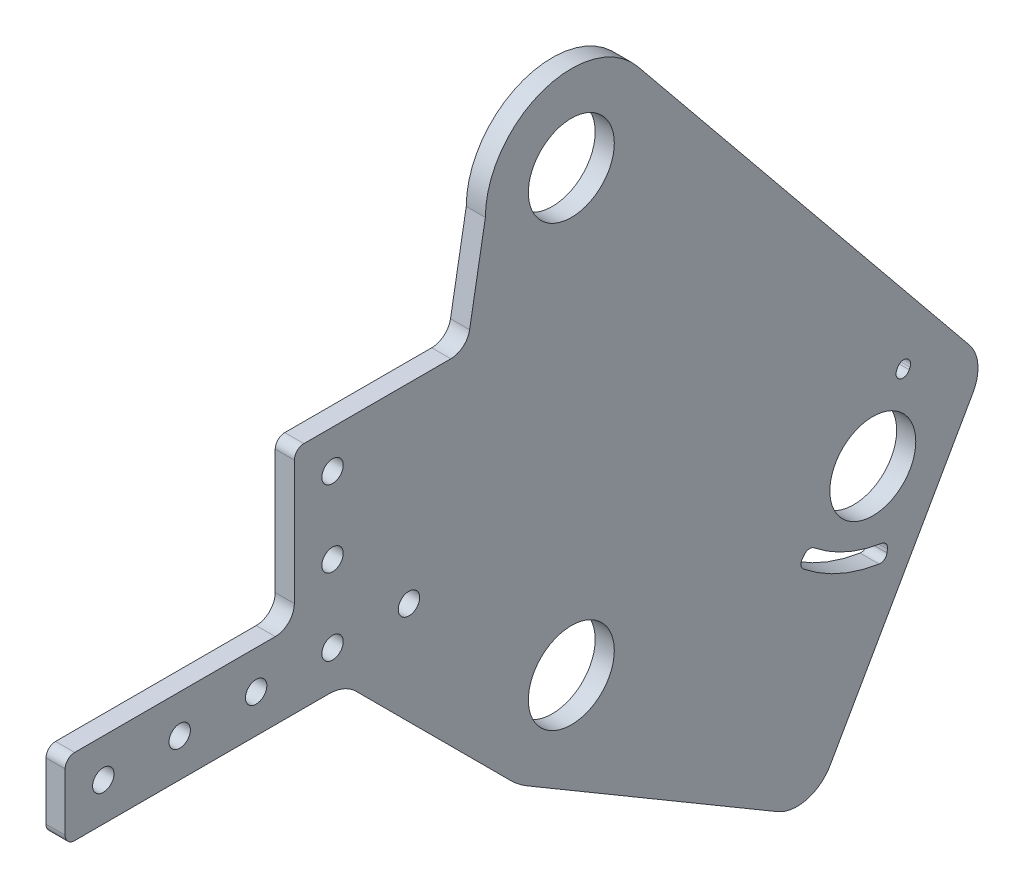
from build123d import *

# Parameters (mm, degrees)
SKETCH2_R           = 14.2875
SKETCH2_R_2         = 3.556
BOSS_EXTRUDE1_DEPTH = 6.35


with BuildPart() as part:
    # Sketch2 → Boss-Extrude1 (new body)
    with BuildSketch(Plane(origin=(0, 0, 0), x_dir=(0, 0, -1), z_dir=(1, 0, 0))):
        with BuildLine():
            Line((-165.1, 34.925), (-80.596664787, 34.925))
            ThreePointArc((-80.596664787, 34.925), (-75.736585196, 33.958270063), (-71.616408666, 31.205256121))
            Line((-71.616408666, 31.205256121), (-20.205576272, -20.205576272))
            ThreePointArc((-20.205576272, -20.205576272), (-17.495774254, -22.592664922), (-14.50653847, -24.618914814))
            Line((-14.50653847, -24.618914814), (68.578013642, -73.575957012))
            ThreePointArc((68.578013642, -73.575957012), (78.454344121, -74.862548761), (86.221769537, -68.628422964))
            Line((86.221769537, -68.628422964), (133.536181692, 14.57458872))
            ThreePointArc((133.536181692, 14.57458872), (135.152284875, 21.909694343), (132.341634936, 28.875023547))
            Line((132.341634936, 28.875023547), (22.151863474, 164.100639036))
            ThreePointArc((22.151863474, 164.100639036), (-9.579695356, 172.971368128), (-28.575, 146.05))
            Line((-28.575, 146.05), (-33.807973228, 116.372334072))
            ThreePointArc((-33.807973228, 116.372334072), (-35.979801138, 112.610617786), (-40.061502459, 111.125))
            Line((-40.061502459, 111.125), (-88.9, 111.125))
            ThreePointArc((-88.9, 111.125), (-91.14506403, 110.19506403), (-92.075, 107.95))
            Line((-92.075, 107.95), (-92.075, 66.675))
            ThreePointArc((-92.075, 66.675), (-93.934871939, 62.184871939), (-98.425, 60.325))
            Line((-98.425, 60.325), (-165.1, 60.325))
            ThreePointArc((-165.1, 60.325), (-167.34506403, 59.39506403), (-168.275, 57.15))
            Line((-168.275, 57.15), (-168.275, 38.1))
            ThreePointArc((-168.275, 38.1), (-167.34506403, 35.85493597), (-165.1, 34.925))
        make_face()
        with Locations((0, 146.05)):
            Circle(SKETCH2_R, mode=Mode.SUBTRACT)
        Circle(SKETCH2_R, mode=Mode.SUBTRACT)
        with Locations((-53.975, 47.625)):
            Circle(SKETCH2_R_2, mode=Mode.SUBTRACT)
        with Locations((-79.375, 47.625)):
            Circle(SKETCH2_R_2, mode=Mode.SUBTRACT)
        with Locations((-104.775, 47.625)):
            Circle(SKETCH2_R_2, mode=Mode.SUBTRACT)
        with Locations((-130.175, 47.625)):
            Circle(SKETCH2_R_2, mode=Mode.SUBTRACT)
        with Locations((-155.575, 47.625)):
            Circle(SKETCH2_R_2, mode=Mode.SUBTRACT)
        with Locations((100.217738322, 10.071728166)):
            Circle(SKETCH2_R, mode=Mode.SUBTRACT)
        with Locations((-79.375, 73.025)):
            Circle(SKETCH2_R_2, mode=Mode.SUBTRACT)
        with Locations((-79.375, 98.425)):
            Circle(SKETCH2_R_2, mode=Mode.SUBTRACT)
        with BuildLine():
            Line((108.137843951, 33.631444269), (108.400752916, 34.22590106))
            ThreePointArc((108.400752916, 34.22590106), (111.416042328, 35.39192926), (112.582070528, 32.376639848))
            Line((112.582070528, 32.376639848), (112.319161563, 31.782183057))
            ThreePointArc((112.319161563, 31.782183057), (109.303872151, 30.616154857), (108.137843951, 33.631444269))
        make_face(mode=Mode.SUBTRACT)
        with BuildLine():
            Line((77.477027734, -4.031327927), (76.839593557, -4.822487627))
            ThreePointArc((76.839593557, -4.822487627), (76.346823941, -6.501290334), (77.185475983, -8.036823849))
            ThreePointArc((77.185475983, -8.036823849), (89.019434317, -15.248472927), (102.316672427, -19.151537226))
            ThreePointArc((102.316672427, -19.151537226), (104.016943026, -18.738886877), (104.927428038, -17.244826147))
            Line((104.927428038, -17.244826147), (105.083882379, -16.24094466))
            ThreePointArc((105.083882379, -16.24094466), (104.67123203, -14.54067406), (103.1771713, -13.630189049))
            ThreePointArc((103.1771713, -13.630189049), (91.279642465, -10.137973624), (80.691363956, -3.685445501))
            ThreePointArc((80.691363956, -3.685445501), (79.012561249, -3.192675886), (77.477027734, -4.031327927))
        make_face(mode=Mode.SUBTRACT)
    extrude(amount=BOSS_EXTRUDE1_DEPTH)


solid = part.part
